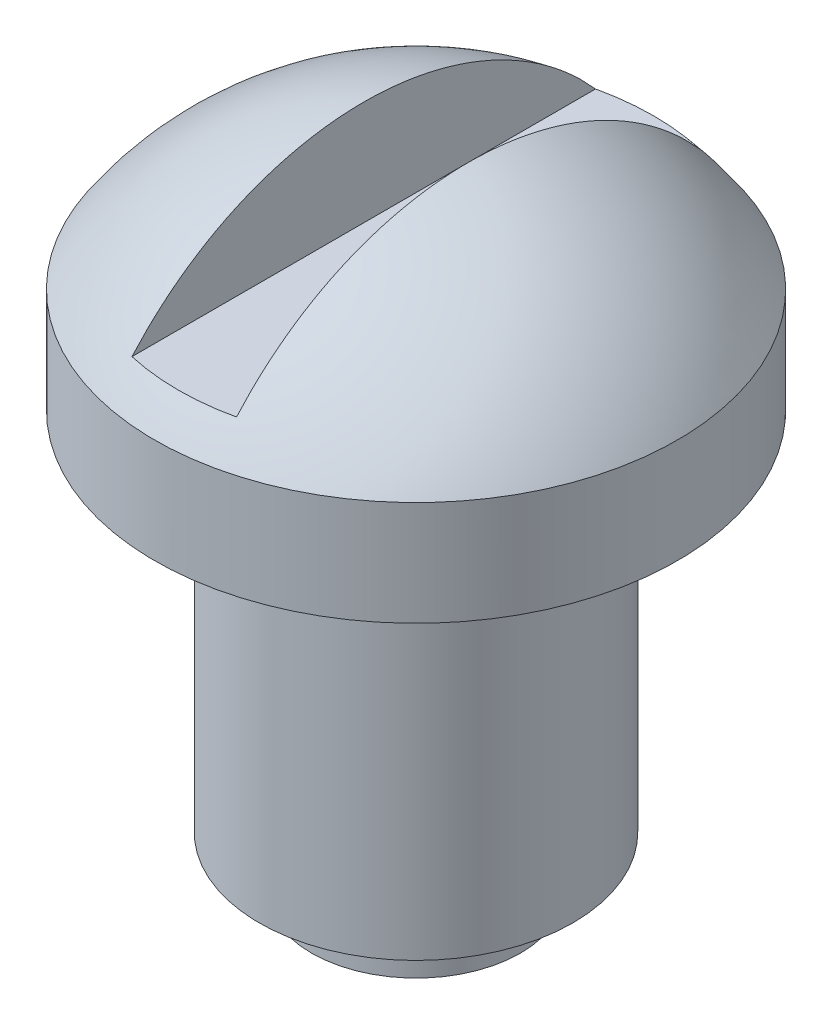
from build123d import *

# Parameters (mm, degrees)
CUT_EXTRUDE5_DEPTH      = 6
CUT_EXTRUDE5_DEPTH_BACK = 6
SKETCH3_R               = 3
BOSS_EXTRUDE1_DEPTH     = 7
SKETCH4_R               = 2
BOSS_EXTRUDE2_DEPTH     = 1


with BuildPart() as part:
    # Sketch1 → Revolve1 (revolve)
    with BuildSketch(Plane.XY):
        with BuildLine():
            Line((0, -1), (5, -1))
            Line((5, -1), (5, 1))
            ThreePointArc((5, 1), (2.837274331, 2.970139283), (0, 3.68337521))
            Line((0, 3.68337521), (0, -1))
        make_face()
    revolve(axis=Axis((0, 3.68337521, 0), (0, -1, 0)))

    # Sketch2 → Cut-Extrude5 (cut, two sides)
    with BuildSketch(Plane.XY) as cut_extrude5_sk:
        Polygon((-1, 28.719638355), (-1, 3.599454993), (-1, 1.599454993), (1, 1.599454993), (1, 3.599454993), (1, 28.719638355), (1, 78.960005081), (-1, 78.960005081), align=None)
    extrude(amount=CUT_EXTRUDE5_DEPTH, mode=Mode.SUBTRACT)
    extrude(cut_extrude5_sk.sketch, amount=-CUT_EXTRUDE5_DEPTH_BACK, mode=Mode.SUBTRACT)

    # Sketch3 → Boss-Extrude1 (add)
    with BuildSketch(Plane.XZ.offset(1)):
        Circle(SKETCH3_R)
    extrude(amount=BOSS_EXTRUDE1_DEPTH)

    # Sketch4 → Boss-Extrude2 (add)
    with BuildSketch(Plane.XZ.offset(8)):
        Circle(SKETCH4_R)
    extrude(amount=BOSS_EXTRUDE2_DEPTH)


solid = part.part
